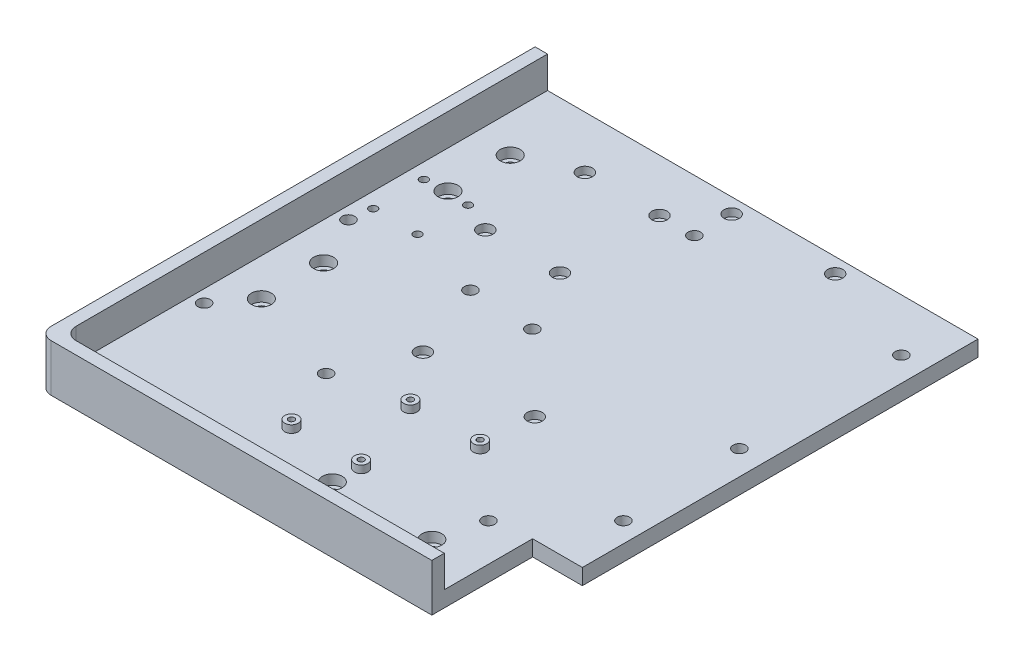
from build123d import *

# Parameters (mm, degrees)
SKETCH1_W                      = 158
SKETCH1_H                      = 199.5
BOSS_EXTRUDE1_DEPTH            = 6.35
BOSS_EXTRUDE2_DEPTH            = 12.7
CBORE_FOR_M4_SHCS1_D           = 4.5
CBORE_FOR_M4_SHCS1_DEPTH       = 6.35
CBORE_FOR_M4_SHCS1_CBORE_D     = 8
CBORE_FOR_M4_SHCS1_CBORE_DEPTH = 4
FILLET2_R                      = 5
SKETCH11_W                     = 20
SKETCH11_H                     = 159
BOSS_EXTRUDE3_DEPTH            = 6.35
SKETCH12_R                     = 2.5
NUCLEO_DEPTH                   = 7.35
SKETCH13_R                     = 2.5
PIHOLDER_DEPTH                 = 7.35
SKETCH14_R                     = 2.5
ESTOP_DEPTH                    = 7.35
SKETCH15_R                     = 2.7
SKETCH15_R_2                   = 1.2
BUCKEXTRUDE_DEPTH              = 3
SKETCH16_R                     = 1.6
BUCKCUT_DEPTH                  = 7.35
LPATTERN1_COUNT                = 2
LPATTERN1_PITCH                = 28
SKETCH17_R                     = 1.6
IMU_DEPTH                      = 7.35
SKETCH19_R                     = 3.05
CUT_EXTRUDE8_DEPTH             = 3.1


with BuildPart() as part:
    # Sketch1 → Boss-Extrude1 (new body)
    with BuildSketch(Plane(origin=(0, 0, 0), x_dir=(1, 0, 0), z_dir=(0, 1, 0))):
        with Locations((79, -99.75)):
            Rectangle(SKETCH1_W, SKETCH1_H)
    extrude(amount=BOSS_EXTRUDE1_DEPTH)

    # Sketch3 → Boss-Extrude2 (add)
    with BuildSketch(Plane(origin=(0, 6.35, 0), x_dir=(1, 0, 0), z_dir=(0, 1, 0))):
        Polygon((0, 0), (0, -199.5), (158, -199.5), (158, -194.5), (5, -194.5), (5, 0), align=None)
    extrude(amount=BOSS_EXTRUDE2_DEPTH)

    # CBORE for M4 SHCS1
    with Locations(Plane(origin=(0, 6.35, 0), x_dir=(1, 0, 0), z_dir=(0, 1, 0))):
        with Locations((20, -55), (98, -179.5), (138, -179.5), (20, -130), (20, -105), (20, -30)):
            CounterBoreHole(CBORE_FOR_M4_SHCS1_D / 2, CBORE_FOR_M4_SHCS1_CBORE_D / 2, CBORE_FOR_M4_SHCS1_CBORE_DEPTH, depth=CBORE_FOR_M4_SHCS1_DEPTH)

    # Fillet2
    fillet2_edges = [part.edges().sort_by_distance(p)[0] for p in [
        (5, 12.7, 194.5),
        (0, 9.525, 199.5),
    ]]
    fillet(fillet2_edges, radius=FILLET2_R)

    # Sketch11 → Boss-Extrude3 (add)
    with BuildSketch(Plane(origin=(0, 6.35, 0), x_dir=(1, 0, 0), z_dir=(0, 1, 0))):
        with Locations((168, -79.5)):
            Rectangle(SKETCH11_W, SKETCH11_H)
    extrude(amount=-BOSS_EXTRUDE3_DEPTH)

    # Sketch12 → Nucleo (cut, through all)
    with BuildSketch(Plane(origin=(0, 6.35, 0), x_dir=(1, 0, 0), z_dir=(0, 1, 0))):
        with Locations((168.2, -21)):
            Circle(SKETCH12_R)
        with Locations((168.2, -86.1)):
            Circle(SKETCH12_R)
        with Locations((85, -86.1)):
            Circle(SKETCH12_R)
        with Locations((85, -21)):
            Circle(SKETCH12_R)
    extrude(amount=-NUCLEO_DEPTH, mode=Mode.SUBTRACT)

    # Sketch13 → PIHolder (cut, through all)
    with BuildSketch(Plane(origin=(0, 6.35, 0), x_dir=(1, 0, 0), z_dir=(0, 1, 0))):
        with Locations((59, -143)):
            Circle(SKETCH13_R)
        with Locations((10, -143)):
            Circle(SKETCH13_R)
        with Locations((10, -85)):
            Circle(SKETCH13_R)
        with Locations((59, -85)):
            Circle(SKETCH13_R)
    extrude(amount=-PIHOLDER_DEPTH, mode=Mode.SUBTRACT)

    # Sketch14 → ESTOP (cut, through all)
    with BuildSketch(Plane(origin=(0, 6.35, 0), x_dir=(1, 0, 0), z_dir=(0, 1, 0))):
        with Locations((170, -134.5)):
            Circle(SKETCH14_R)
        with Locations((142.875, -161.625)):
            Circle(SKETCH14_R)
    extrude(amount=-ESTOP_DEPTH, mode=Mode.SUBTRACT)

    # Sketch15 → BuckExtrude (add)
    with BuildSketch(Plane(origin=(0, 6.35, 0), x_dir=(1, 0, 0), z_dir=(0, 1, 0))):
        with Locations((116, -138.1)):
            Circle(SKETCH15_R)
        with Locations((116, -138.1)):
            Circle(SKETCH15_R_2, mode=Mode.SUBTRACT)
        with Locations((99, -168.9)):
            Circle(SKETCH15_R)
        with Locations((99, -168.9)):
            Circle(SKETCH15_R_2, mode=Mode.SUBTRACT)
    buckextrude = extrude(amount=BUCKEXTRUDE_DEPTH)

    # Sketch16 → BuckCut (cut, through all)
    with BuildSketch(Plane(origin=(0, 6.35, 0), x_dir=(1, 0, 0), z_dir=(0, 1, 0))):
        with Locations((99, -168.9)):
            Circle(SKETCH16_R)
        with Locations((116, -138.1)):
            Circle(SKETCH16_R)
    buckcut = extrude(amount=-BUCKCUT_DEPTH, mode=Mode.SUBTRACT)

    # LPattern1: BuckExtrude, BuckCut ×2
    with Locations(*[(-i * LPATTERN1_PITCH, 0, 0) for i in range(1, LPATTERN1_COUNT)]):
        add(buckextrude)
        add(buckcut, mode=Mode.SUBTRACT)

    # Sketch17 → IMU (cut, through all)
    with BuildSketch(Plane(origin=(0, 6.35, 0), x_dir=(1, 0, 0), z_dir=(0, 1, 0))):
        with Locations((28.89, -55.84)):
            Circle(SKETCH17_R)
        with Locations((28.89, -76.16)):
            Circle(SKETCH17_R)
        with Locations((11.11, -76.16)):
            Circle(SKETCH17_R)
        with Locations((11.11, -55.84)):
            Circle(SKETCH17_R)
    extrude(amount=-IMU_DEPTH, mode=Mode.SUBTRACT)

    # Sketch19 → Cut-Extrude8 (cut)
    with BuildSketch(Plane(origin=(0, 6.35, 0), x_dir=(1, 0, 0), z_dir=(0, 1, 0))):
        with Locations((126.6, -6)):
            Circle(SKETCH19_R)
        with Locations((85, -6)):
            Circle(SKETCH19_R)
        with Locations((116, -116.1)):
            Circle(SKETCH19_R)
        with Locations((71, -116.1)):
            Circle(SKETCH19_R)
        with Locations((71, -21)):
            Circle(SKETCH19_R)
        with Locations((71, -61)):
            Circle(SKETCH19_R)
        with Locations((41, -61)):
            Circle(SKETCH19_R)
        with Locations((41, -21)):
            Circle(SKETCH19_R)
    extrude(amount=-CUT_EXTRUDE8_DEPTH, mode=Mode.SUBTRACT)


solid = part.part
